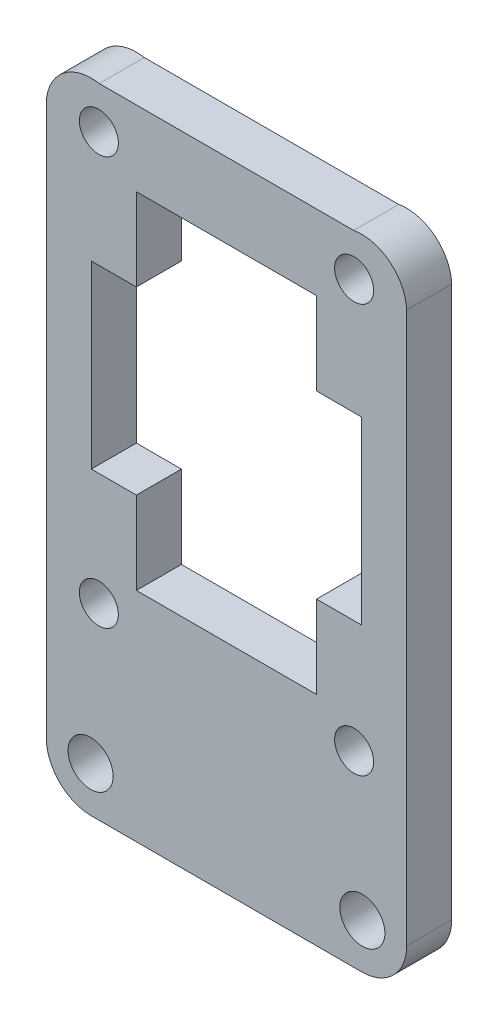
from build123d import *

# Parameters (mm, degrees)
MODEL_R             = 1.298950001
MODEL_R_2           = 1.499950004
BOSS_EXTRUDE1_DEPTH = 3


with BuildPart() as part:
    # Model → Boss-Extrude1 (new body)
    with BuildSketch(Plane.XY):
        with BuildLine():
            Line((72.2662, 46.25), (72.2662, 56.421043711))
            ThreePointArc((72.2662, 56.421043711), (71.145459643, 58.637903109), (68.738, 59.25))
            Line((68.738, 59.25), (51.7943, 59.25))
            ThreePointArc((51.7943, 59.25), (49.381832487, 58.63325007), (48.2662, 56.4071))
            Line((48.2662, 56.4071), (48.2662, 46.25))
            Line((48.2662, 46.25), (48.2662, 19.75))
            ThreePointArc((48.2662, 19.75), (49.144899998, 17.628699998), (51.2662, 16.75))
            Line((51.2662, 16.75), (69.2662, 16.75))
            ThreePointArc((69.2662, 16.75), (71.387450001, 17.628749999), (72.2662, 19.75))
            Line((72.2662, 19.75), (72.2662, 46.25))
        make_face()
        with Locations((51.76615, 56.45005)):
            Circle(MODEL_R, mode=Mode.SUBTRACT)
        with Locations((68.76615, 56.45005)):
            Circle(MODEL_R, mode=Mode.SUBTRACT)
        with Locations((51.76615, 29.25005)):
            Circle(MODEL_R, mode=Mode.SUBTRACT)
        with Locations((68.76615, 29.25005)):
            Circle(MODEL_R, mode=Mode.SUBTRACT)
        with Locations((51.216249997, 19.750049997)):
            Circle(MODEL_R_2, mode=Mode.SUBTRACT)
        with Locations((69.316249997, 19.750049997)):
            Circle(MODEL_R_2, mode=Mode.SUBTRACT)
        Polygon((69.2662, 48.75), (69.2662, 36.75), (66.2662, 36.75), (66.2662, 31.25), (54.2662, 31.25), (54.2662, 36.75), (51.2662, 36.75), (51.2662, 48.75), (54.2662, 48.75), (54.2662, 54.25), (66.2662, 54.25), (66.2662, 48.75), align=None, mode=Mode.SUBTRACT)
    extrude(amount=BOSS_EXTRUDE1_DEPTH)


solid = part.part
